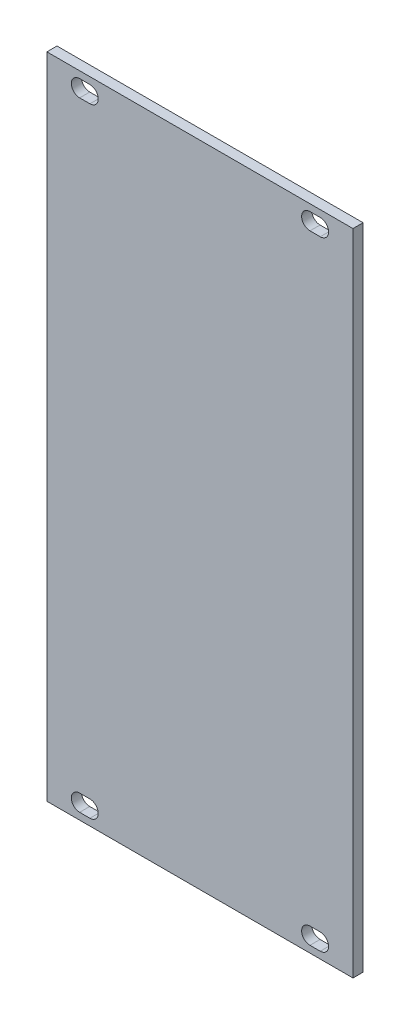
from build123d import *

# Parameters (mm, degrees)
SKETCH1_W           = 60.6
SKETCH1_H           = 128.5
BOSS_EXTRUDE1_DEPTH = 2


with BuildPart() as part:
    # Sketch1 → Boss-Extrude1 (new body)
    with BuildSketch(Plane.XY):
        Rectangle(SKETCH1_W, SKETCH1_H)
        with BuildLine():
            Line((-23.816, -59.6), (-21.784, -59.6))
            ThreePointArc((-21.784, -59.6), (-20.134, -61.25), (-21.784, -62.9))
            Line((-21.784, -62.9), (-23.816, -62.9))
            ThreePointArc((-23.816, -62.9), (-25.466, -61.25), (-23.816, -59.6))
        make_face(mode=Mode.SUBTRACT)
        with BuildLine():
            Line((-23.816, 62.9), (-21.784, 62.9))
            ThreePointArc((-21.784, 62.9), (-20.134, 61.25), (-21.784, 59.6))
            Line((-21.784, 59.6), (-23.816, 59.6))
            ThreePointArc((-23.816, 59.6), (-25.466, 61.25), (-23.816, 62.9))
        make_face(mode=Mode.SUBTRACT)
        with BuildLine():
            Line((21.784000014, 62.9), (23.816000014, 62.9))
            ThreePointArc((23.816000014, 62.9), (25.466000014, 61.25), (23.816000014, 59.6))
            Line((23.816000014, 59.6), (21.784000014, 59.6))
            ThreePointArc((21.784000014, 59.6), (20.134000014, 61.25), (21.784000014, 62.9))
        make_face(mode=Mode.SUBTRACT)
        with BuildLine():
            Line((21.784000014, -59.6), (23.816000014, -59.6))
            ThreePointArc((23.816000014, -59.6), (25.466000014, -61.25), (23.816000014, -62.9))
            Line((23.816000014, -62.9), (21.784000014, -62.9))
            ThreePointArc((21.784000014, -62.9), (20.134000014, -61.25), (21.784000014, -59.6))
        make_face(mode=Mode.SUBTRACT)
    extrude(amount=BOSS_EXTRUDE1_DEPTH)


solid = part.part
